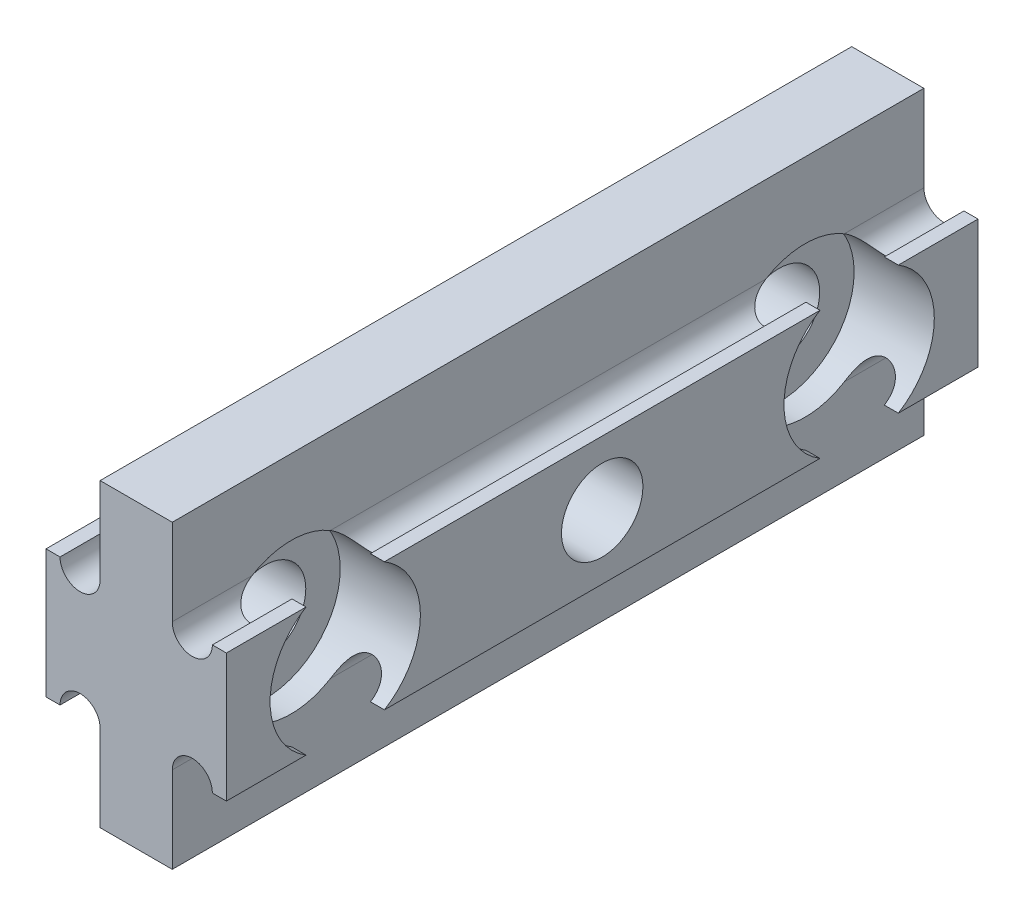
from build123d import *

# Parameters (mm, degrees)
BOSS_EXTRUDE1_DEPTH = 23.8125
SKETCH2_R           = 2.5796875
CUT_EXTRUDE1_DEPTH  = 12.43
SKETCH3_R           = 4.7625
CUT_EXTRUDE2_DEPTH  = 5.08


with BuildPart() as part:
    # Sketch1 → Boss-Extrude1 (new body, symmetric)
    with BuildSketch(Plane.XY):
        with BuildLine():
            Line((0, -9.525), (0, 9.525))
            Line((0, 9.525), (-2.286, 9.525))
            Line((-2.286, 9.525), (-2.286, 4.064))
            ThreePointArc((-2.286, 4.064), (-3.556, 2.794), (-4.826, 4.064))
            Line((-4.826, 4.064), (-5.715, 4.064))
            Line((-5.715, 4.064), (-5.715, -4.064))
            Line((-5.715, -4.064), (-4.826, -4.064))
            ThreePointArc((-4.826, -4.064), (-3.556, -2.794), (-2.286, -4.064))
            Line((-2.286, -4.064), (-2.286, -9.525))
            Line((-2.286, -9.525), (0, -9.525))
        make_face()
    boss_extrude1 = extrude(amount=BOSS_EXTRUDE1_DEPTH, both=True)

    # Mirror1: Boss-Extrude1 across plane
    add(boss_extrude1.mirror(Plane(origin=(0, -9.525, 23.8125), x_dir=(0, 0, 1), z_dir=(-1, 0, 0))))

    # Sketch2 → Cut-Extrude1 (cut, through all)
    with BuildSketch(Plane(origin=(5.715, 0, 0), x_dir=(0, 0, -1), z_dir=(1, 0, 0))):
        with Locations((-16.2814, 0)):
            Circle(SKETCH2_R)
        with Locations((16.2814, 0)):
            Circle(SKETCH2_R)
        Circle(SKETCH2_R)
    extrude(amount=-CUT_EXTRUDE1_DEPTH, mode=Mode.SUBTRACT)

    # Sketch3 → Cut-Extrude2 (cut)
    with BuildSketch(Plane(origin=(5.715, 0, 0), x_dir=(0, 0, -1), z_dir=(1, 0, 0))):
        with Locations((-16.2814, 0)):
            Circle(SKETCH3_R)
        with Locations((16.2814, 0)):
            Circle(SKETCH3_R)
    extrude(amount=-CUT_EXTRUDE2_DEPTH, mode=Mode.SUBTRACT)


solid = part.part
